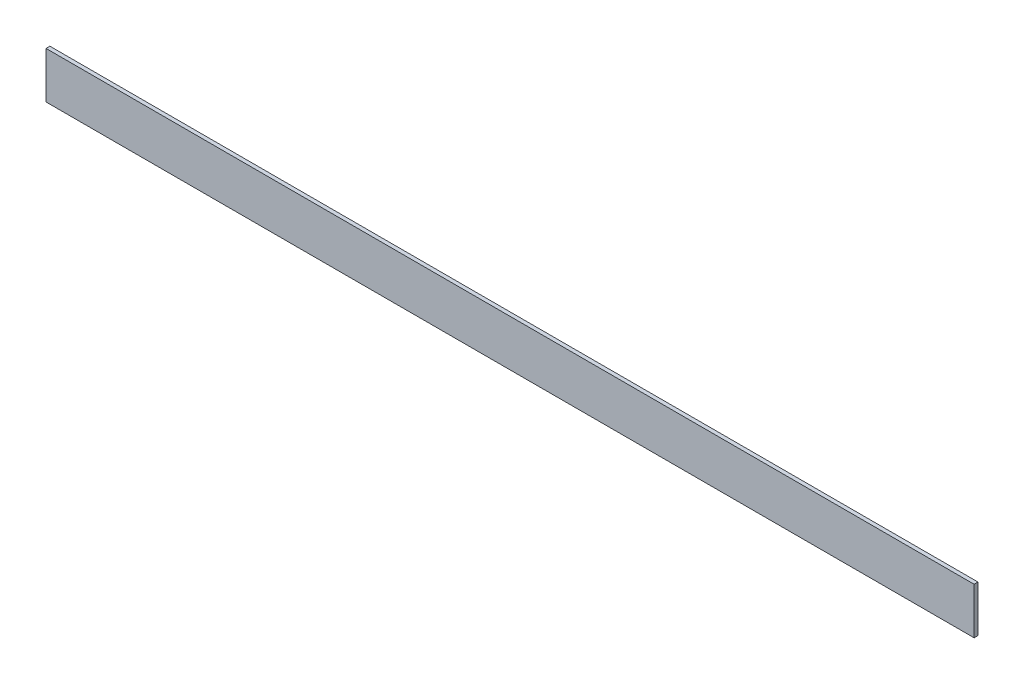
from build123d import *

# Parameters (mm, degrees)
SKETCH1_W           = 6.35
SKETCH1_H           = 76.2
BOSS_EXTRUDE1_DEPTH = 1524


with BuildPart() as part:
    # Sketch1 → Boss-Extrude1 (new body)
    with BuildSketch(Plane(origin=(0, 0, 0), x_dir=(0, 0, -1), z_dir=(1, 0, 0))):
        Rectangle(SKETCH1_W, SKETCH1_H)
    extrude(amount=BOSS_EXTRUDE1_DEPTH)


solid = part.part
